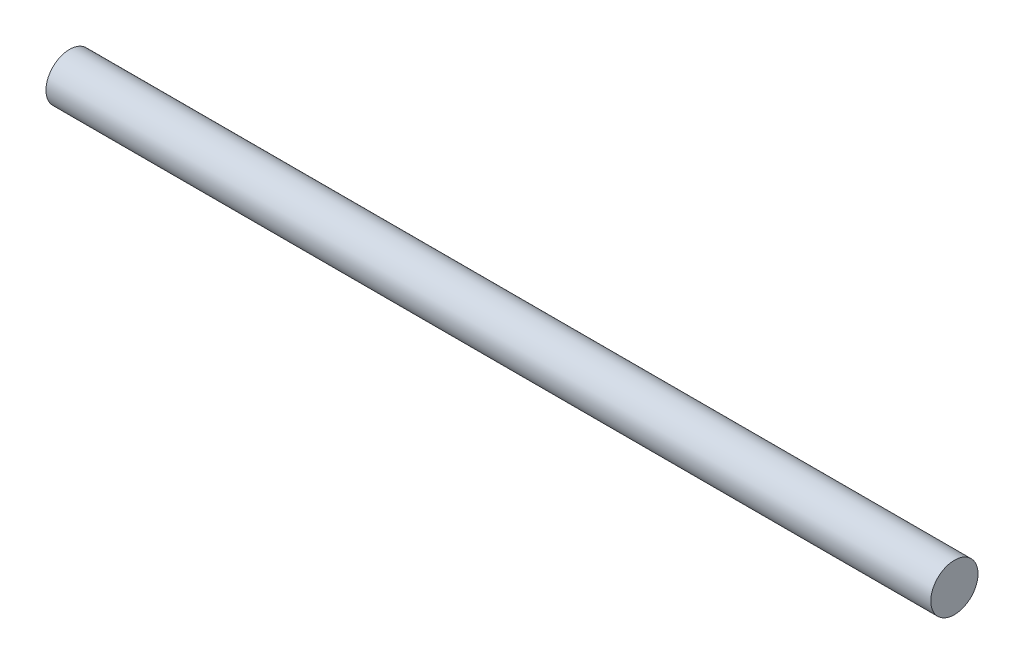
from build123d import *

# Parameters (mm, degrees)
SCHIZZO1_R                   = 2
ESTRUSIONE_ESTRUSIONE1_DEPTH = 75


with BuildPart() as part:
    # Schizzo1 → Estrusione-Estrusione1 (new body)
    with BuildSketch(Plane(origin=(0, 0, 0), x_dir=(0, 0, -1), z_dir=(1, 0, 0))):
        Circle(SCHIZZO1_R)
    extrude(amount=ESTRUSIONE_ESTRUSIONE1_DEPTH)


solid = part.part
